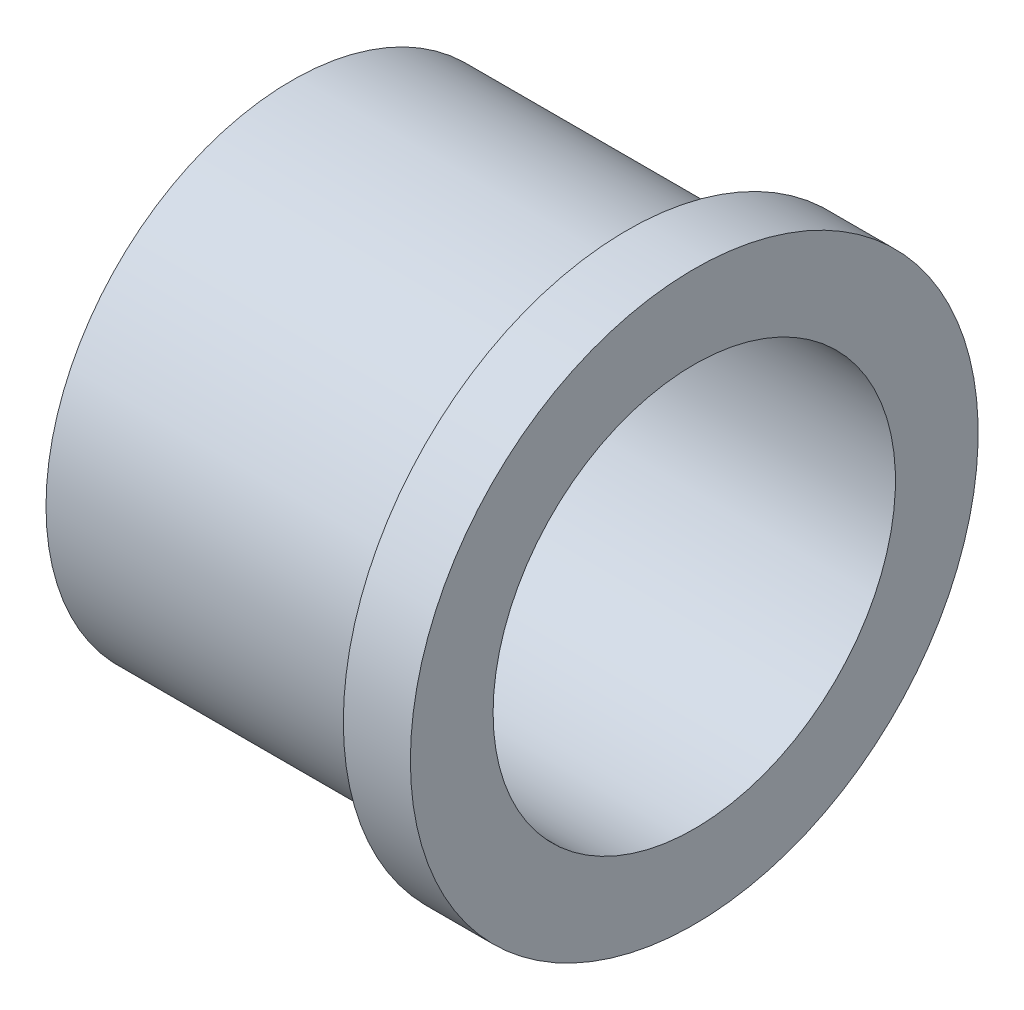
from build123d import *


with BuildPart() as part:
    # Sketch1 → Revolve1 (revolve)
    with BuildSketch(Plane(origin=(0, 0, 0), x_dir=(1, 0, 0), z_dir=(0, 1, 0))):
        Polygon((0, 12.7), (0, 11), (-15, 11), (-15, 9), (3, 9), (3, 12.7), align=None)
    revolve(axis=Axis((-93.58907888, 0, 0), (1, 0, 0)))


solid = part.part
